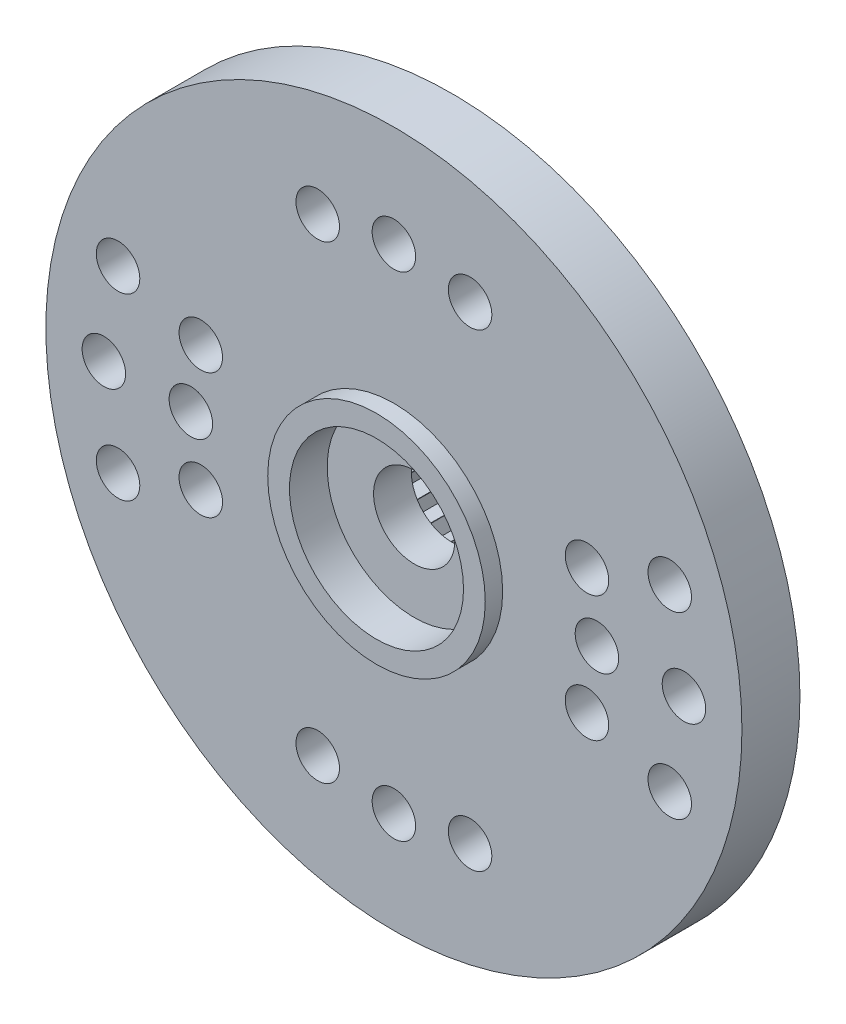
from build123d import *

# Parameters (mm, degrees)
ESQUISSE1_R                  = 4.5
BOSS_EXTRU_1_DEPTH           = 3
ESQUISSE2_R                  = 12
ESQUISSE2_R_2                = 1.4
BOSS_EXTRU_2_DEPTH           = 2
ESQUISSE3_R                  = 3.75
ESQUISSE3_R_2                = 1.4
BOSS_EXTRU_3_DEPTH           = 0.6
ESQUISSE4_R                  = 3
ENL_V_MAT_EXTRU_1_DEPTH      = 1.3
ESQUISSE5_R                  = 0.75
ENL_V_MAT_EXTRU_2_DEPTH      = 6
R_P_TITION_CIRCULAIRE1_COUNT = 20
ESQUISSE6_R                  = 0.75
ENL_V_MAT_EXTRU_3_DEPTH      = 6
R_P_TITION_CIRCULAIRE2_COUNT = 20


with BuildPart() as part:
    # Esquisse1 → Boss.-Extru.1 (new body)
    with BuildSketch(Plane.XY):
        Circle(ESQUISSE1_R)
        Polygon((2.011577371, -1.550856692), (2.011577371, -2.011577371), (1.550856692, -2.011577371), (1.541643286, -2.018647066), (1.4224, -2.463669069), (0.977377998, -2.344425783), (0.966648759, -2.348869979), (0.73628842, -2.747865791), (0.337292608, -2.517505451), (0.325778716, -2.519021284), (0, -2.8448), (-0.325778716, -2.519021284), (-0.337292608, -2.517505451), (-0.73628842, -2.747865791), (-0.966648759, -2.348869979), (-0.977377998, -2.344425783), (-1.4224, -2.463669069), (-1.541643286, -2.018647066), (-1.550856692, -2.011577371), (-2.011577371, -2.011577371), (-2.011577371, -1.550856692), (-2.018647066, -1.541643286), (-2.463669069, -1.4224), (-2.344425783, -0.977377998), (-2.348869979, -0.966648759), (-2.747865791, -0.73628842), (-2.517505451, -0.337292608), (-2.519021284, -0.325778716), (-2.8448, 0), (-2.519021284, 0.325778716), (-2.517505451, 0.337292608), (-2.747865791, 0.73628842), (-2.348869979, 0.966648759), (-2.344425783, 0.977377998), (-2.463669069, 1.4224), (-2.018647066, 1.541643286), (-2.011577371, 1.550856692), (-2.011577371, 2.011577371), (-1.550856692, 2.011577371), (-1.541643286, 2.018647066), (-1.4224, 2.463669069), (-0.977377998, 2.344425783), (-0.966648759, 2.348869979), (-0.73628842, 2.747865791), (-0.337292608, 2.517505451), (-0.325778716, 2.519021284), (0, 2.8448), (0.325778716, 2.519021284), (0.337292608, 2.517505451), (0.73628842, 2.747865791), (0.966648759, 2.348869979), (0.977377998, 2.344425783), (1.4224, 2.463669069), (1.541643286, 2.018647066), (1.550856692, 2.011577371), (2.011577371, 2.011577371), (2.011577371, 1.550856692), (2.018647066, 1.541643286), (2.463669069, 1.4224), (2.344425783, 0.977377998), (2.348869979, 0.966648759), (2.747865791, 0.73628842), (2.517505451, 0.337292608), (2.519021284, 0.325778716), (2.8448, 0), (2.519021284, -0.325778716), (2.517505451, -0.337292608), (2.747865791, -0.73628842), (2.348869979, -0.966648759), (2.344425783, -0.977377998), (2.463669069, -1.4224), (2.018647066, -1.541643286), align=None, mode=Mode.SUBTRACT)
    extrude(amount=BOSS_EXTRU_1_DEPTH)

    # Esquisse2 → Boss.-Extru.2 (add)
    with BuildSketch(Plane.XY.offset(3)):
        Circle(ESQUISSE2_R)
        Circle(ESQUISSE2_R_2, mode=Mode.SUBTRACT)
    extrude(amount=BOSS_EXTRU_2_DEPTH)

    # Esquisse3 → Boss.-Extru.3 (add)
    with BuildSketch(Plane.XY.offset(5)):
        Circle(ESQUISSE3_R)
        Circle(ESQUISSE3_R_2, mode=Mode.SUBTRACT)
    extrude(amount=BOSS_EXTRU_3_DEPTH)

    # Esquisse4 → Enlèv. mat.-Extru.1 (cut)
    with BuildSketch(Plane.XY.offset(5.6)):
        Circle(ESQUISSE4_R)
    extrude(amount=-ENL_V_MAT_EXTRU_1_DEPTH, mode=Mode.SUBTRACT)

    # Esquisse5 → Enlèv. mat.-Extru.2 (cut, through all)
    with BuildSketch(Plane.XY.offset(5)):
        with Locations((-10, 0)):
            Circle(ESQUISSE5_R)
        with Locations((-7, 0)):
            Circle(ESQUISSE5_R)
    enl_v_mat_extru_2 = extrude(amount=-ENL_V_MAT_EXTRU_2_DEPTH, mode=Mode.SUBTRACT)

    # Répétition circulaire1: Enlèv. mat.-Extru.2 ×20 about axis, 14 skipped
    r_p_tition_circulaire1_axis = Axis((0, 0, 0), (0, 0, 1))
    add([enl_v_mat_extru_2.rotate(r_p_tition_circulaire1_axis, i * 360 / R_P_TITION_CIRCULAIRE1_COUNT) for i in range(1, R_P_TITION_CIRCULAIRE1_COUNT) if i not in (2, 3, 4, 5, 6, 7, 8, 12, 13, 14, 15, 16, 17, 18)], mode=Mode.SUBTRACT)

    # Esquisse6 → Enlèv. mat.-Extru.3 (cut, through all)
    with BuildSketch(Plane.XY.offset(5)):
        with Locations((0, 8.5)):
            Circle(ESQUISSE6_R)
    enl_v_mat_extru_3 = extrude(amount=-ENL_V_MAT_EXTRU_3_DEPTH, mode=Mode.SUBTRACT)

    # Répétition circulaire2: Enlèv. mat.-Extru.3 ×20 about axis, 14 skipped
    r_p_tition_circulaire2_axis = Axis((0, 0, 0), (0, 0, 1))
    add([enl_v_mat_extru_3.rotate(r_p_tition_circulaire2_axis, i * 360 / R_P_TITION_CIRCULAIRE2_COUNT) for i in range(1, R_P_TITION_CIRCULAIRE2_COUNT) if i not in (2, 3, 4, 5, 6, 7, 8, 12, 13, 14, 15, 16, 17, 18)], mode=Mode.SUBTRACT)


solid = part.part
